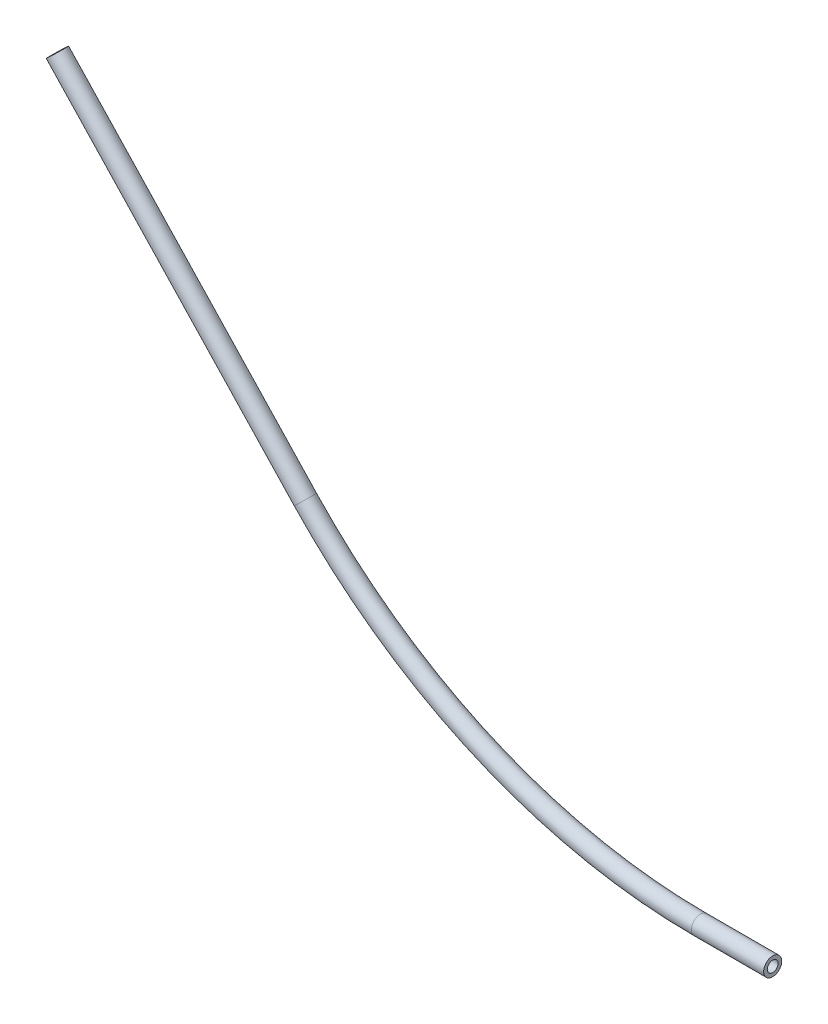
from build123d import *

# Parameters (mm, degrees)
SKETCH1_R   = 3.175
SKETCH1_R_2 = 1.905


with BuildPart() as part:
    # Sweep2: sweep along a path in Sketch2
    with BuildLine(Plane.XY) as sweep2_path:
        Line((0, 0), (-25.4, 0))
        ThreePointArc((-25.4, 0), (-100.951042868, 15.622071371), (-164.110864908, 59.926090062))
        Line((-164.110864908, 59.926090062), (-251.1601382, 152.4))
    # Sketch1 → Sweep2 (sweep)
    with BuildSketch(Plane(origin=(0, 0, 0), x_dir=(0, 0, -1), z_dir=(1, 0, 0))):
        Circle(SKETCH1_R)
        Circle(SKETCH1_R_2, mode=Mode.SUBTRACT)
    sweep(path=sweep2_path.line)


solid = part.part
